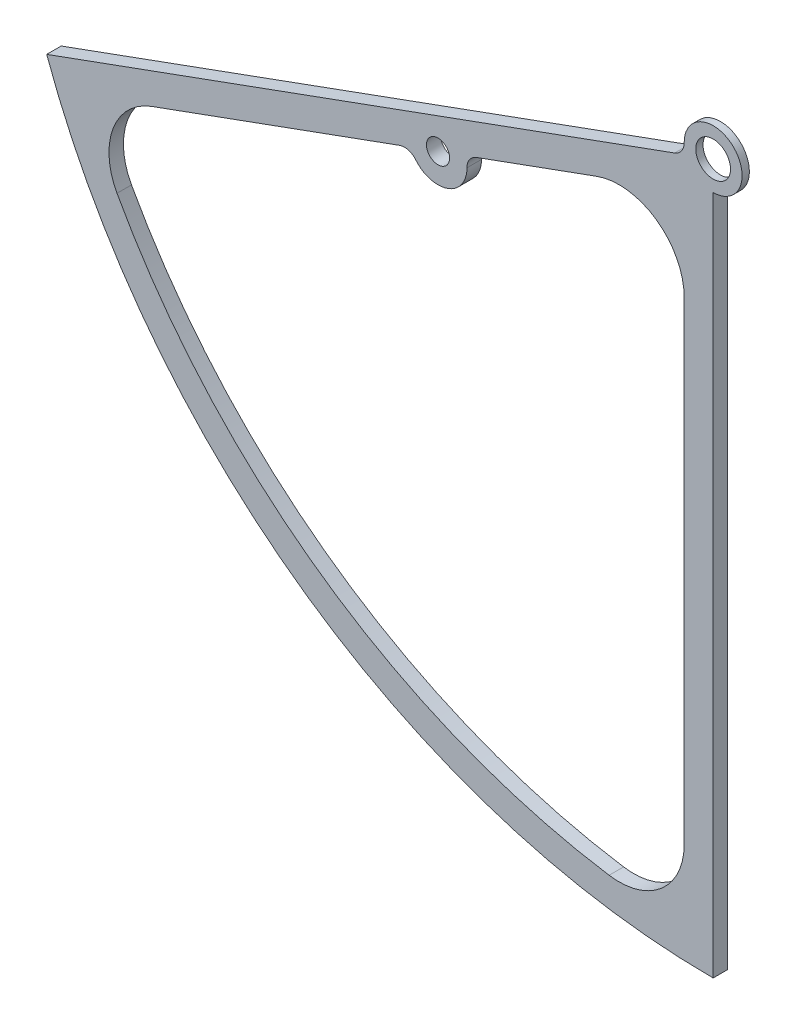
from build123d import *

# Parameters (mm, degrees)
SZKIC1_R                    = 12
SZKIC1_R_2                  = 8
DODANIE_WYCI_GNI_CIE1_DEPTH = 10
SZKIC2_R                    = 20
WYTNIJ_WYCI_GNI_CIE1_DEPTH  = 5
ZAOKR_GLENIE1_R             = 45
ZAOKR_GLENIE2_R             = 10


with BuildPart() as part:
    # Szkic1 → Dodanie-wyciągnięcie1 (new body)
    with BuildSketch(Plane.XY):
        with BuildLine():
            Line((0, -20), (0, -490))
            ThreePointArc((0, -490), (-281.052453812, -401.384501702), (-460.449384185, -167.58987023))
            Line((-460.449384185, -167.58987023), (-18.793852416, -6.840402867))
            ThreePointArc((-18.793852416, -6.840402867), (11.471528727, 16.383040886), (0, -20))
        make_face()
        Circle(SZKIC1_R, mode=Mode.SUBTRACT)
        with Locations((-190.094997116, -90.472476083)):
            Circle(SZKIC1_R_2, mode=Mode.SUBTRACT)
        with BuildLine():
            Line((-20, -28.562960135), (-20, -469.574275275))
            ThreePointArc((-20, -469.574275275), (-269.580925085, -385.001460816), (-434.41507852, -179.397713347))
            Line((-434.41507852, -179.397713347), (-208.888849532, -97.312878949))
            ThreePointArc((-208.888849532, -97.312878949), (-183.254594249, -109.266328498), (-171.3011447, -83.632073216))
            Line((-171.3011447, -83.632073216), (-20, -28.562960135))
        make_face(mode=Mode.SUBTRACT)
    extrude(amount=DODANIE_WYCI_GNI_CIE1_DEPTH)

    # Szkic2 → Wytnij-wyciągnięcie1 (cut)
    with BuildSketch(Plane(origin=(0, 0, 0), x_dir=(-1, 0, 0), z_dir=(0, 0, -1))):
        Circle(SZKIC2_R)
    extrude(amount=-WYTNIJ_WYCI_GNI_CIE1_DEPTH, mode=Mode.SUBTRACT)

    # Zaokrąglenie1
    zaokr_glenie1_edges = [part.edges().sort_by_distance(p)[0] for p in [
        (-434.41507852, -179.397713347, 5),
        (-20, -469.574275275, 5),
        (-20, -28.562960135, 5),
    ]]
    fillet(zaokr_glenie1_edges, radius=ZAOKR_GLENIE1_R)

    # Zaokrąglenie2
    zaokr_glenie2_edges = [part.edges().sort_by_distance(p)[0] for p in [
        (-171.3011447, -83.632073216, 5),
        (-208.888849532, -97.312878949, 5),
        (-18.793852416, -6.840402867, 7.5),
    ]]
    fillet(zaokr_glenie2_edges, radius=ZAOKR_GLENIE2_R)


solid = part.part
